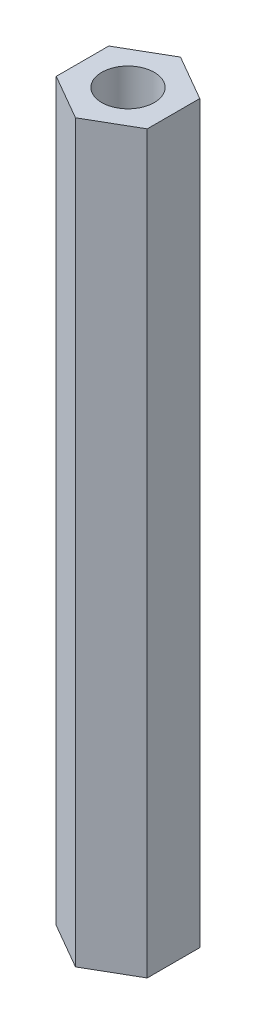
from build123d import *

# Parameters (mm, degrees)
ESQUISSE1_R      = 2.5
EXTRUSION1_DEPTH = 70


with BuildPart() as part:
    # Esquisse1 → Extrusion1 (new body)
    with BuildSketch(Plane(origin=(0, 0, 0), x_dir=(1, 0, 0), z_dir=(0, 1, 0))):
        Polygon((0, 5), (-4.330127019, 2.5), (-4.330127019, -2.5), (0, -5), (4.330127019, -2.5), (4.330127019, 2.5), align=None)
        Circle(ESQUISSE1_R, mode=Mode.SUBTRACT)
    extrude(amount=EXTRUSION1_DEPTH)


solid = part.part
